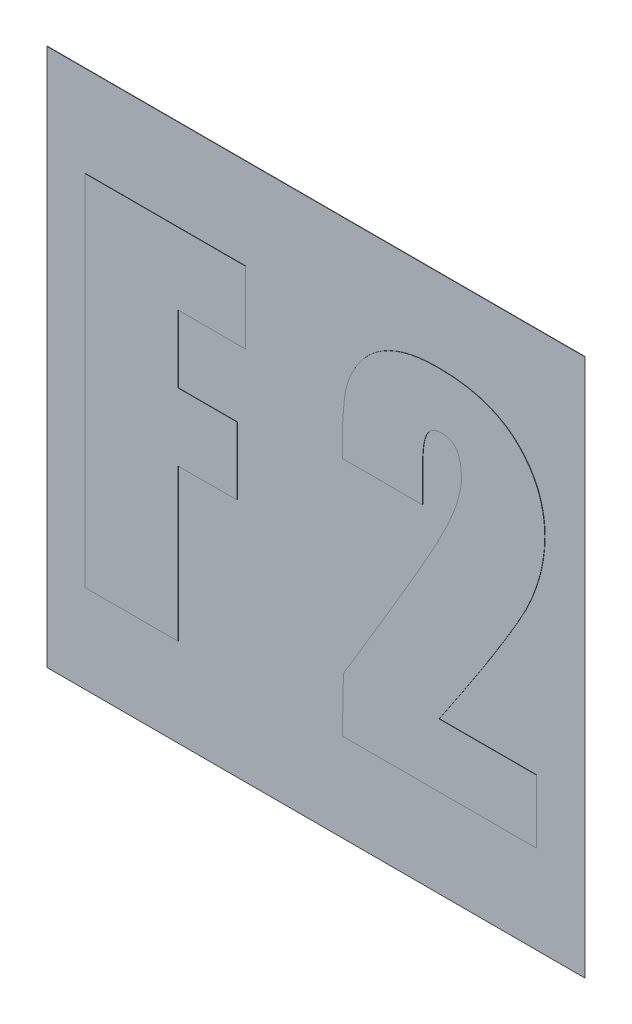
from build123d import *

# Parameters (mm, degrees)
SKETCH1_W           = 15
SKETCH1_H           = 15
BASE_EXTRUDE_DEPTH  = 0.01
BOSS_EXTRUDE1_DEPTH = 0.01


with BuildPart() as part:
    # Sketch1 → Base-Extrude (new body)
    with BuildSketch(Plane.XY):
        Rectangle(SKETCH1_W, SKETCH1_H)
    extrude(amount=BASE_EXTRUDE_DEPTH)

    # Sketch3 → Boss-Extrude1 (add)
    with BuildSketch(Plane.XY.offset(0.01)):
        Polygon((-6.422687471, 4.966697862), (-1.95437388, 4.966697862), (-1.95437388, 2.967715466), (-3.835769076, 2.967715466), (-3.835769076, 1.08632027), (-2.189548279, 1.08632027), (-2.189548279, -0.795074926), (-3.835769076, -0.795074926), (-3.835769076, -5.028214117), (-6.422687471, -5.028214117), align=None)
        with BuildLine():
            Line((6.159142904, -3.264406121), (6.159142904, -5.028214117))
            Line((6.159142904, -5.028214117), (0.750131715, -5.028214117))
            Line((0.750131715, -5.028214117), (0.779528515, -3.499580521))
            add(Edge.make_bspline(
                [(0.779528515, -3.499580521), (0.877014083, -3.338576188), (1.066979862, -3.024834225), (1.343045705, -2.56480754), (1.602681012, -2.128002305), (1.850432695, -1.716510192), (2.079193397, -1.326713925), (2.294345848, -0.961203267), (2.494671208, -0.619498336), (2.679973751, -0.301493491), (2.851966968, -0.007907642), (3.004887743, 0.263950757), (3.145640195, 0.510739163), (3.270514365, 0.733991797), (3.3786378, 0.934750039), (3.473207235, 1.111300707), (3.551330736, 1.264877002), (3.636598876, 1.434182645), (3.725717962, 1.624674223), (3.817352242, 1.840530263), (3.894914579, 2.044060275), (3.960461689, 2.233412865), (4.006982766, 2.411483456), (4.046334489, 2.574975972), (4.066429896, 2.727136462), (4.070191411, 2.824363225), (4.071970108, 2.870338566)],
                knots=[0, 0, 0, 0, 0.000564652, 0.001100313, 0.001609507, 0.002089081, 0.002541254, 0.002965388, 0.003361483, 0.00372954, 0.004069559, 0.004382224, 0.004665264, 0.004921882, 0.005149603, 0.005349329, 0.005522708, 0.005666499, 0.005918015, 0.006153476, 0.00636981, 0.00657142, 0.006754155, 0.006921752, 0.007075582, 0.007213575, 0.007213575, 0.007213575, 0.007213575], degree=3))
            add(Edge.make_bspline(
                [(4.071970108, 2.870338566), (4.070068672, 2.933484515), (4.066508767, 3.051707609), (4.04433705, 3.217001799), (4.002738782, 3.357003396), (3.943565001, 3.472371568), (3.867169386, 3.564598818), (3.769499006, 3.629208641), (3.653793224, 3.66631058), (3.571275415, 3.67085994), (3.528129309, 3.673238665)],
                knots=[0, 0, 0, 0, 0.000189465, 0.00035472, 0.000498851, 0.000625412, 0.000741395, 0.000854011, 0.000971956, 0.001101209, 0.001101209, 0.001101209, 0.001101209], degree=3))
            add(Edge.make_bspline(
                [(3.528129309, 3.673238665), (3.484910432, 3.671163948), (3.401853536, 3.667176812), (3.285749318, 3.625396077), (3.188411854, 3.554676877), (3.125112869, 3.473103812), (3.084579248, 3.393226095), (3.05651705, 3.3188966), (3.036714643, 3.230759277), (3.014954485, 3.130743563), (3.000980696, 3.016402907), (2.993317763, 2.888767878), (2.984453815, 2.747962897), (2.984345395, 2.649879731), (2.98428851, 2.598418167)],
                knots=[0, 0, 0, 0, 0.000129252, 0.000248394, 0.000364158, 0.000485823, 0.000554026, 0.000632516, 0.00072342, 0.000824672, 0.000939529, 0.001068468, 0.001208296, 0.00136264, 0.00136264, 0.00136264, 0.00136264], degree=3))
            Line((2.98428851, 2.598418167), (2.98428851, 1.674256269))
            Line((2.98428851, 1.674256269), (0.750131715, 1.674256269))
            Line((0.750131715, 1.674256269), (0.750131715, 2.032529768))
            add(Edge.make_bspline(
                [(0.750131715, 2.032529768), (0.751022306, 2.16238688), (0.752707687, 2.408132412), (0.769457747, 2.75497652), (0.794121954, 3.058519518), (0.829016676, 3.326551357), (0.8889659, 3.572609948), (0.980977076, 3.808592891), (1.100992692, 4.043964564), (1.252566069, 4.272463253), (1.429507662, 4.48928336), (1.638168026, 4.678306609), (1.871509665, 4.838617245), (2.129530989, 4.972884244), (2.414907456, 5.074410455), (2.724975997, 5.15020006), (3.062040959, 5.194068001), (3.295275309, 5.19920968), (3.416054009, 5.201872262)],
                knots=[0, 0, 0, 0, 0.000389547, 0.00073719, 0.001041434, 0.001303086, 0.001547281, 0.001799098, 0.002061221, 0.002338435, 0.002620255, 0.00289858, 0.003179903, 0.003467515, 0.003768586, 0.004086312, 0.004423595, 0.004785841, 0.004785841, 0.004785841, 0.004785841], degree=3))
            add(Edge.make_bspline(
                [(3.416054009, 5.201872262), (3.534966431, 5.200080949), (3.765988513, 5.196600802), (4.101222792, 5.160428229), (4.414479271, 5.105247103), (4.705518743, 5.023904179), (4.974089205, 4.91969881), (5.220309249, 4.792782177), (5.443526672, 4.64230899), (5.643566838, 4.469806168), (5.819026319, 4.278351536), (5.973160681, 4.074852589), (6.103805742, 3.859461087), (6.211974397, 3.632193542), (6.292222673, 3.39113189), (6.350412677, 3.138911047), (6.389348309, 2.874602653), (6.392639634, 2.69409963), (6.394317303, 2.602092767)],
                knots=[0, 0, 0, 0, 0.000356607, 0.000692812, 0.001010304, 0.001309874, 0.001597838, 0.001873127, 0.00213913, 0.00240358, 0.002663621, 0.002916802, 0.00316825, 0.003418103, 0.003670262, 0.003928747, 0.004194038, 0.004469854, 0.004469854, 0.004469854, 0.004469854], degree=3))
            add(Edge.make_bspline(
                [(6.394317303, 2.602092767), (6.392746801, 2.530392619), (6.389573077, 2.385498544), (6.368416534, 2.166525542), (6.335496514, 1.944494313), (6.289237681, 1.718691614), (6.228852902, 1.490592136), (6.154009792, 1.259261118), (6.068593193, 1.024462193), (5.983251437, 0.825045072), (5.903440559, 0.656268599), (5.831206174, 0.511348432), (5.744678172, 0.350644217), (5.645434225, 0.172419472), (5.533178231, -0.022253367), (5.408235872, -0.23355711), (5.269714361, -0.461563791), (5.12022609, -0.707268255), (4.955268897, -0.968500781), (4.779876872, -1.248181418), (4.588522389, -1.542420961), (4.386080467, -1.854729454), (4.169155651, -2.182111033), (3.941284953, -2.528915012), (3.699482969, -2.89155892), (3.532558952, -3.138340923), (3.447288109, -3.264406121)],
                knots=[0, 0, 0, 0, 0.00021509, 0.00043466, 0.00065942, 0.000888229, 0.00112576, 0.001366894, 0.001617421, 0.001875076, 0.002017262, 0.002177487, 0.002360785, 0.002564758, 0.002789458, 0.003034921, 0.003301178, 0.003589815, 0.003897721, 0.004228026, 0.004580179, 0.004950663, 0.00534457, 0.00575835, 0.006195566, 0.006652153, 0.006652153, 0.006652153, 0.006652153], degree=3))
            Line((3.447288109, -3.264406121), (6.159142904, -3.264406121))
        make_face()
    extrude(amount=BOSS_EXTRUDE1_DEPTH)


solid = part.part
